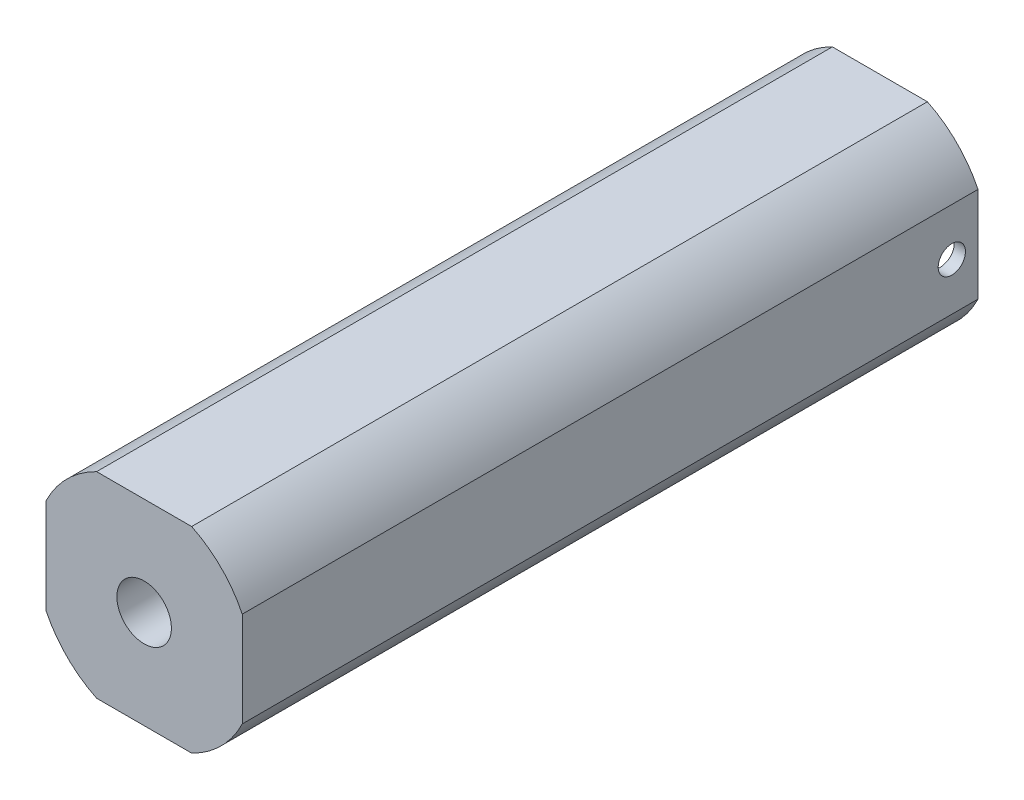
from build123d import *

# Parameters (mm, degrees)
BOSS_EXTRUDE1_DEPTH            = 42.8498
SKETCH4_R                      = 5.05
CUT_EXTRUDE1_DEPTH             = 1.524
F_1_16_0_0625_DIAMETER_HOLE1_D = 1.5875
F_1_8_0_125_DIAMETER_HOLE2_D   = 3.175


with BuildPart() as part:
    # Sketch1 → Boss-Extrude1 (new body)
    with BuildSketch(Plane.XY):
        with BuildLine():
            Line((-2.767900829, 5.715), (2.767900829, 5.715))
            ThreePointArc((2.767900829, 5.715), (4.490128061, 4.490128061), (5.715, 2.767900829))
            Line((5.715, 2.767900829), (5.715, -2.767900829))
            ThreePointArc((5.715, -2.767900829), (4.490128061, -4.490128061), (2.767900829, -5.715))
            Line((2.767900829, -5.715), (-2.767900829, -5.715))
            ThreePointArc((-2.767900829, -5.715), (-4.490128061, -4.490128061), (-5.715, -2.767900829))
            Line((-5.715, -2.767900829), (-5.715, 2.767900829))
            ThreePointArc((-5.715, 2.767900829), (-4.490128061, 4.490128061), (-2.767900829, 5.715))
        make_face()
    extrude(amount=BOSS_EXTRUDE1_DEPTH)

    # Sketch4 → Cut-Extrude1 (cut)
    with BuildSketch(Plane(origin=(0, 0, 0), x_dir=(-1, 0, 0), z_dir=(0, 0, -1))):
        Circle(SKETCH4_R)
    extrude(amount=-CUT_EXTRUDE1_DEPTH, mode=Mode.SUBTRACT)

    # 1/16 (0.0625) Diameter Hole1 (through all)
    with Locations(Plane(origin=(5.715, 0, 0), x_dir=(0, 0, -1), z_dir=(1, 0, 0))):
        with Locations((-1.524, 0)):
            Hole(F_1_16_0_0625_DIAMETER_HOLE1_D / 2)

    # 1/8 (0.125) Diameter Hole2 (through all)
    with Locations(Plane(origin=(0, 0, 1.524), x_dir=(-1, 0, 0), z_dir=(0, 0, -1))):
        with Locations((0, 0)):
            Hole(F_1_8_0_125_DIAMETER_HOLE2_D / 2)


solid = part.part
